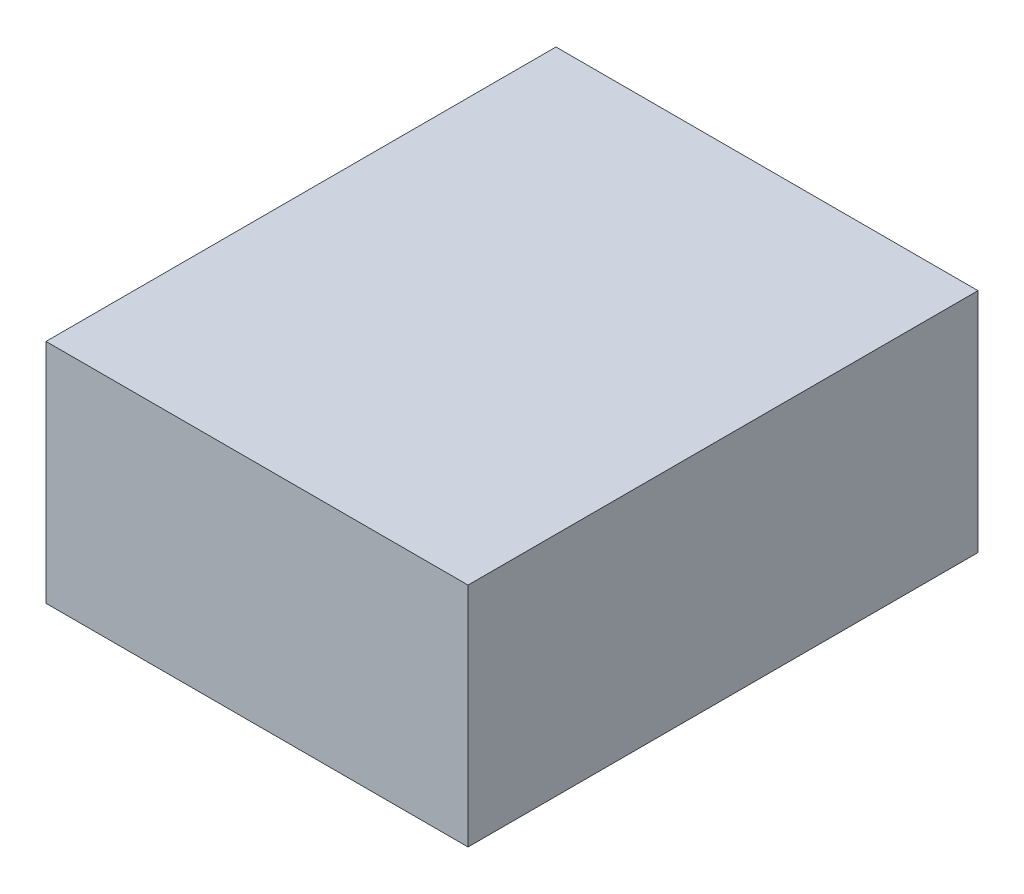
from build123d import *

# Parameters (mm, degrees)
SKETCH1_W           = 240
SKETCH1_H           = 129
BOSS_EXTRUDE1_DEPTH = 290


with BuildPart() as part:
    # Sketch1 → Boss-Extrude1 (new body)
    with BuildSketch(Plane.XY):
        Rectangle(SKETCH1_W, SKETCH1_H)
    extrude(amount=BOSS_EXTRUDE1_DEPTH)


solid = part.part
